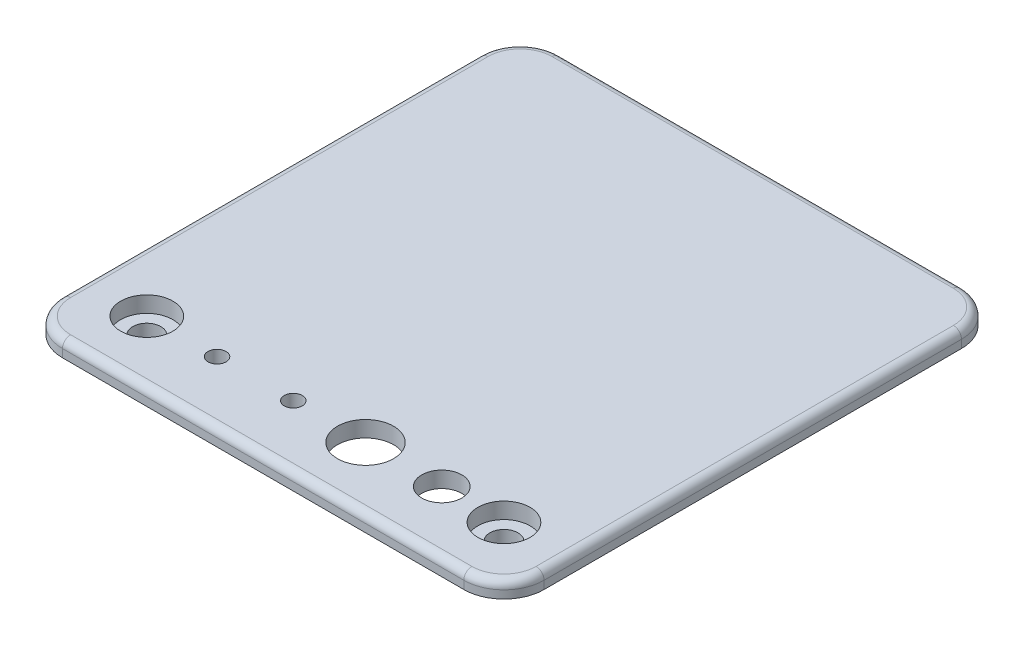
from build123d import *

# Parameters (mm, degrees)
SKETCH1_R           = 1.125
SKETCH1_R_2         = 2.5
SKETCH1_R_3         = 3.5
BOSS_EXTRUDE1_DEPTH = 2
SKETCH2_R           = 4
BOSS_EXTRUDE2_DEPTH = 2
SKETCH3_R           = 1.75
CUT_EXTRUDE1_DEPTH  = 5
SKETCH4_R           = 3.25
SKETCH4_R_2         = 1.75
CUT_EXTRUDE2_DEPTH  = 2
SKETCH6_W           = 20
SKETCH6_H           = 2.75
BOSS_EXTRUDE3_DEPTH = 4
CUT_EXTRUDE3_DEPTH  = 16
FILLET1_R           = 2
FILLET2_R           = 1


with BuildPart() as part:
    # Sketch1 → Boss-Extrude1 (new body)
    with BuildSketch(Plane(origin=(0, 0, 0), x_dir=(1, 0, 0), z_dir=(0, 1, 0))):
        with BuildLine():
            Line((25, -31), (-25, -31))
            ThreePointArc((-25, -31), (-28.535533906, -29.535533906), (-30, -26))
            Line((-30, -26), (-30, 26))
            ThreePointArc((-30, 26), (-28.535533906, 29.535533906), (-25, 31))
            Line((-25, 31), (25, 31))
            ThreePointArc((25, 31), (28.535533906, 29.535533906), (30, 26))
            Line((30, 26), (30, -26))
            ThreePointArc((30, -26), (28.535533906, -29.535533906), (25, -31))
        make_face()
        with Locations((-13.5, -23.25)):
            Circle(SKETCH1_R, mode=Mode.SUBTRACT)
        with Locations((-4, -23.25)):
            Circle(SKETCH1_R, mode=Mode.SUBTRACT)
        with Locations((14.5, -23.25)):
            Circle(SKETCH1_R_2, mode=Mode.SUBTRACT)
        with Locations((5, -23.25)):
            Circle(SKETCH1_R_3, mode=Mode.SUBTRACT)
    extrude(amount=BOSS_EXTRUDE1_DEPTH)

    # Sketch2 → Boss-Extrude2 (add)
    with BuildSketch(Plane.XZ):
        with Locations((-22.25, 23.25)):
            Circle(SKETCH2_R)
        with Locations((22.25, 23.25)):
            Circle(SKETCH2_R)
    extrude(amount=BOSS_EXTRUDE2_DEPTH)

    # Sketch3 → Cut-Extrude1 (cut, through all)
    with BuildSketch(Plane.XZ.offset(2)):
        with Locations((-22.25, 23.25)):
            Circle(SKETCH3_R)
        with Locations((22.25, 23.25)):
            Circle(SKETCH3_R)
    extrude(amount=-CUT_EXTRUDE1_DEPTH, mode=Mode.SUBTRACT)

    # Sketch4 → Cut-Extrude2 (cut)
    with BuildSketch(Plane(origin=(0, 2, 0), x_dir=(1, 0, 0), z_dir=(0, 1, 0))):
        with Locations((-22.25, -23.25)):
            Circle(SKETCH4_R)
        with Locations((-22.25, -23.25)):
            Circle(SKETCH4_R_2, mode=Mode.SUBTRACT)
        with Locations((22.25, -23.25)):
            Circle(SKETCH4_R)
        with Locations((22.25, -23.25)):
            Circle(SKETCH4_R_2, mode=Mode.SUBTRACT)
    extrude(amount=-CUT_EXTRUDE2_DEPTH, mode=Mode.SUBTRACT)

    # Sketch6 → Boss-Extrude3 (add)
    with BuildSketch(Plane.XZ):
        with Locations((0, -27.625)):
            Rectangle(SKETCH6_W, SKETCH6_H)
    extrude(amount=BOSS_EXTRUDE3_DEPTH)

    # Sketch7 → Cut-Extrude3 (cut)
    with BuildSketch(Plane(origin=(8, 0, 0), x_dir=(0, 0, -1), z_dir=(1, 0, 0))):
        Polygon((29, -3), (27, 0), (29, 0), align=None)
    extrude(amount=-CUT_EXTRUDE3_DEPTH, mode=Mode.SUBTRACT)

    # Fillet1
    fillet1_edges = [part.edges().sort_by_distance(p)[0] for p in [
        (10, -4, -27.625),
        (-10, -4, -27.625),
    ]]
    fillet(fillet1_edges, radius=FILLET1_R)

    # Fillet2
    fillet2_edges = [part.edges().sort_by_distance(p)[0] for p in [
        (28.535533906, 2, -29.535533906),
        (0, 2, -31),
        (-28.535533906, 2, -29.535533906),
        (-30, 2, 0),
        (-28.535533906, 2, 29.535533906),
        (0, 2, 31),
        (28.535533906, 2, 29.535533906),
        (30, 2, 0),
    ]]
    fillet(fillet2_edges, radius=FILLET2_R)


solid = part.part
